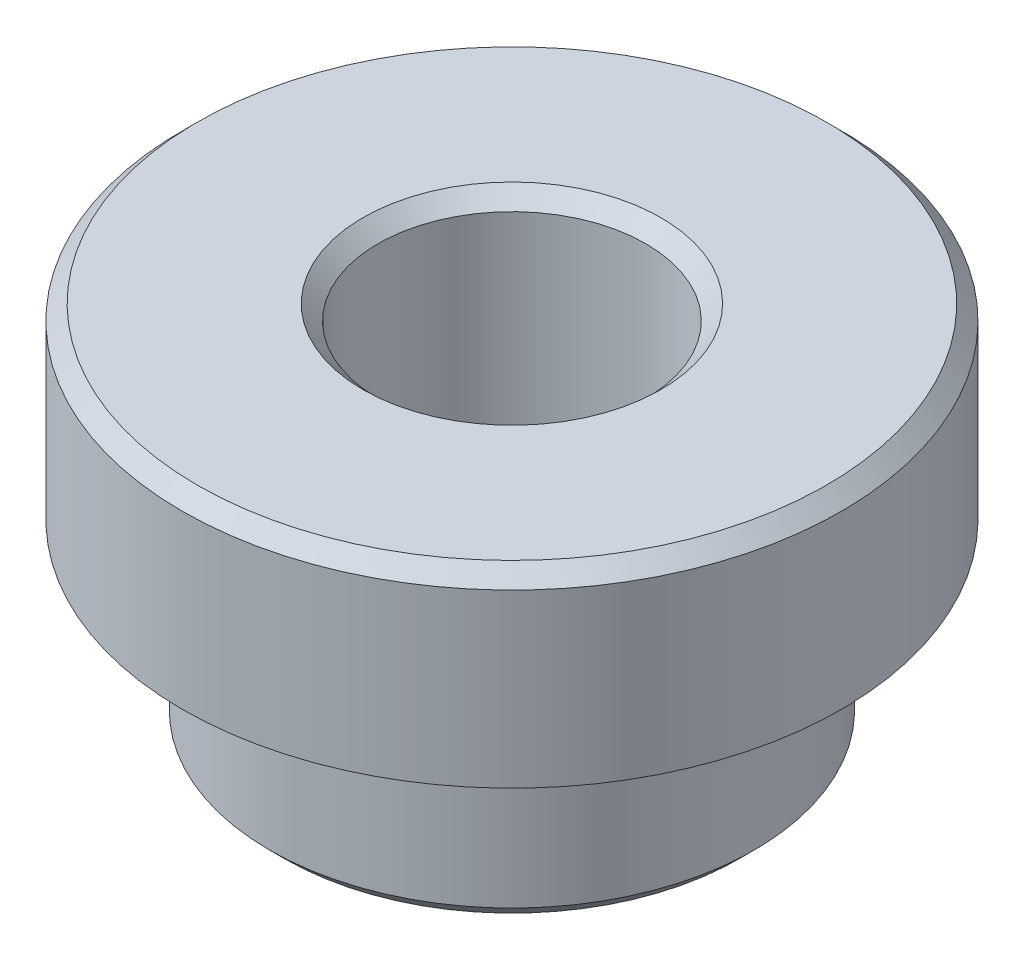
from build123d import *

# Parameters (mm, degrees)
SKETCH1_R             = 2.0447
BOSS_EXTRUDE1_DEPTH   = 1.524
SKETCH2_R             = 2.7813
BOSS_EXTRUDE2_DEPTH   = 1.5748
F_4_40_TAPPED_HOLE1_D = 2.2606
CHAMFER1_SIZE         = 0.127


with BuildPart() as part:
    # Sketch1 → Boss-Extrude1 (new body)
    with BuildSketch(Plane(origin=(0, 0, 0), x_dir=(1, 0, 0), z_dir=(0, 1, 0))):
        Circle(SKETCH1_R)
    extrude(amount=BOSS_EXTRUDE1_DEPTH)

    # Sketch2 → Boss-Extrude2 (add)
    with BuildSketch(Plane(origin=(0, 1.524, 0), x_dir=(1, 0, 0), z_dir=(0, 1, 0))):
        Circle(SKETCH2_R)
    extrude(amount=BOSS_EXTRUDE2_DEPTH)

    # #4-40 Tapped Hole1 (through all)
    with Locations(Plane(origin=(0, 3.0988, 0), x_dir=(1, 0, 0), z_dir=(0, 1, 0))):
        with Locations((0, 0)):
            Hole(F_4_40_TAPPED_HOLE1_D / 2)

    # Chamfer1
    chamfer1_edges = [part.edges().sort_by_distance(p)[0] for p in [
        (1.1303, 3.0988, 0),
        (-2.0447, 0, 0),
        (-2.7813, 3.0988, 0),
    ]]
    chamfer(chamfer1_edges, length=CHAMFER1_SIZE)


solid = part.part
